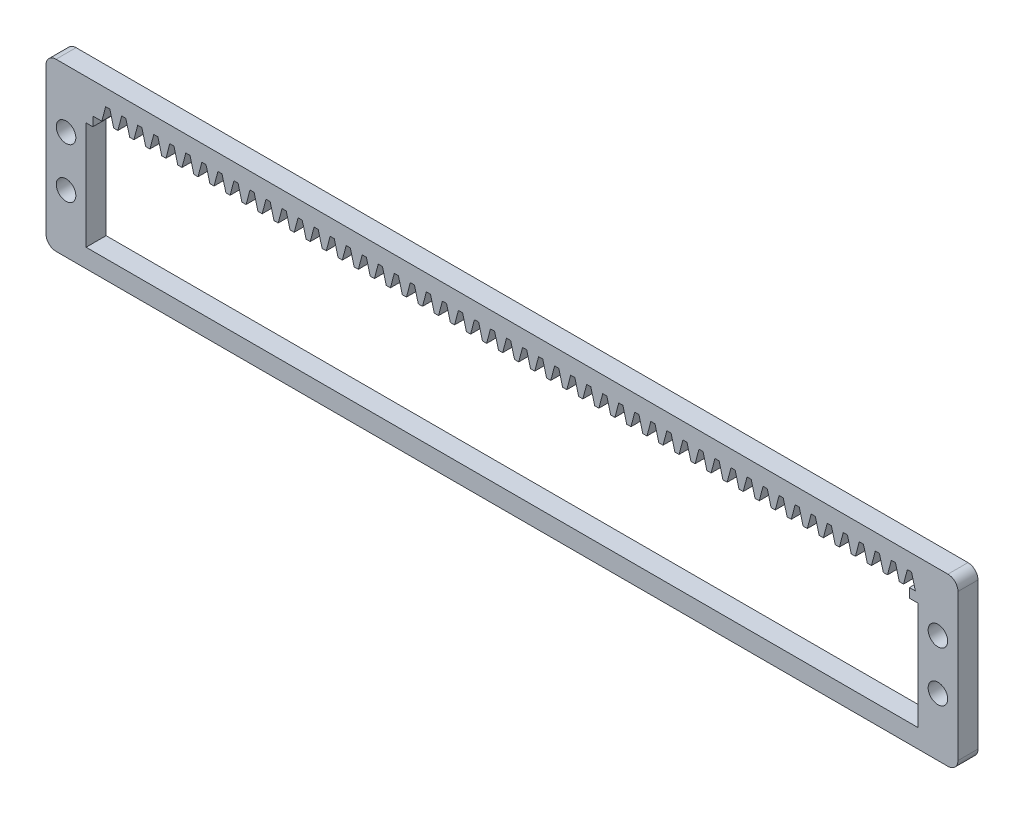
from build123d import *

# Parameters (mm, degrees)
BOSS_EXTRUDE1_DEPTH = 4
SKETCH2_W           = 166
SKETCH2_H           = 21.5
CUT_EXTRUDE1_DEPTH  = 5
SKETCH3_W           = 162.97
SKETCH3_H           = 1.85
CUT_EXTRUDE2_DEPTH  = 5
CUT_EXTRUDE4_DEPTH  = 5
LPATTERN1_COUNT     = 51
LPATTERN1_PITCH     = 3.2
SKETCH5_R           = 1.95
CUT_EXTRUDE5_DEPTH  = 10


with BuildPart() as part:
    # Sketch1 → Boss-Extrude1 (new body)
    with BuildSketch(Plane.XY):
        with BuildLine():
            Line((2, 0), (180, 0))
            ThreePointArc((180, 0), (181.414213562, -0.585786438), (182, -2))
            Line((182, -2), (182, -31.22))
            ThreePointArc((182, -31.22), (181.414213562, -32.634213562), (180, -33.22))
            Line((180, -33.22), (2, -33.22))
            ThreePointArc((2, -33.22), (0.585786438, -32.634213562), (0, -31.22))
            Line((0, -31.22), (0, -2))
            ThreePointArc((0, -2), (0.585786438, -0.585786438), (2, 0))
        make_face()
    extrude(amount=BOSS_EXTRUDE1_DEPTH)

    # Sketch2 → Cut-Extrude1 (cut, through all)
    with BuildSketch(Plane.XY.offset(4)):
        with Locations((91, -18.75)):
            Rectangle(SKETCH2_W, SKETCH2_H)
    extrude(amount=-CUT_EXTRUDE1_DEPTH, mode=Mode.SUBTRACT)

    # Sketch3 → Cut-Extrude2 (cut, through all)
    with BuildSketch(Plane.XY.offset(4)):
        with Locations((90.835, -7.075)):
            Rectangle(SKETCH3_W, SKETCH3_H)
    extrude(amount=-CUT_EXTRUDE2_DEPTH, mode=Mode.SUBTRACT)

    # Sketch4 → Cut-Extrude4 (cut, through all)
    with BuildSketch(Plane.XY.offset(4)):
        Polygon((172.735, -3.249176841), (173.5, -6.15), (171.14, -6.15), (171.905, -3.249176841), align=None)
    cut_extrude4 = extrude(amount=-CUT_EXTRUDE4_DEPTH, mode=Mode.SUBTRACT)

    # LPattern1: Cut-Extrude4 ×51
    with Locations(*[(-i * LPATTERN1_PITCH, 0, 0) for i in range(1, LPATTERN1_COUNT)]):
        add(cut_extrude4, mode=Mode.SUBTRACT)

    # Sketch5 → Cut-Extrude5 (cut)
    with BuildSketch(Plane.XY.offset(4)):
        with Locations((4, -11.61)):
            Circle(SKETCH5_R)
        with Locations((4, -21.61)):
            Circle(SKETCH5_R)
        with Locations((178, -11.61)):
            Circle(SKETCH5_R)
        with Locations((178, -21.61)):
            Circle(SKETCH5_R)
    extrude(amount=-CUT_EXTRUDE5_DEPTH, mode=Mode.SUBTRACT)


solid = part.part
